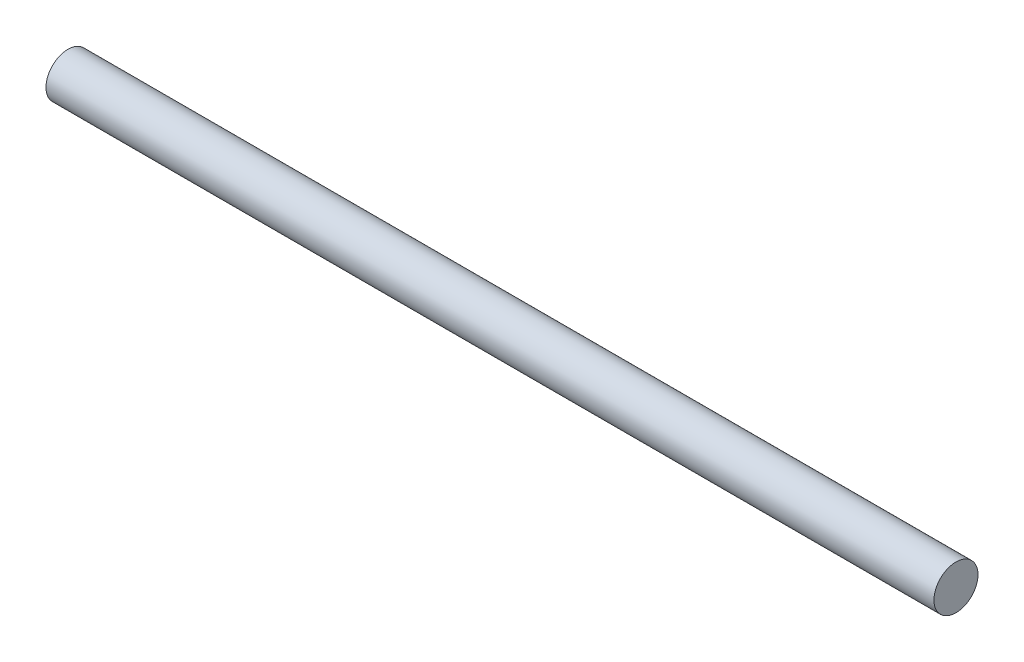
from build123d import *

# Parameters (mm, degrees)
SKETCH1_R           = 1.5875
BOSS_EXTRUDE1_DEPTH = 32


with BuildPart() as part:
    # Sketch1 → Boss-Extrude1 (new body, symmetric)
    with BuildSketch(Plane(origin=(0, 0, 0), x_dir=(0, 0, -1), z_dir=(1, 0, 0))):
        Circle(SKETCH1_R)
    extrude(amount=BOSS_EXTRUDE1_DEPTH, both=True)


solid = part.part
